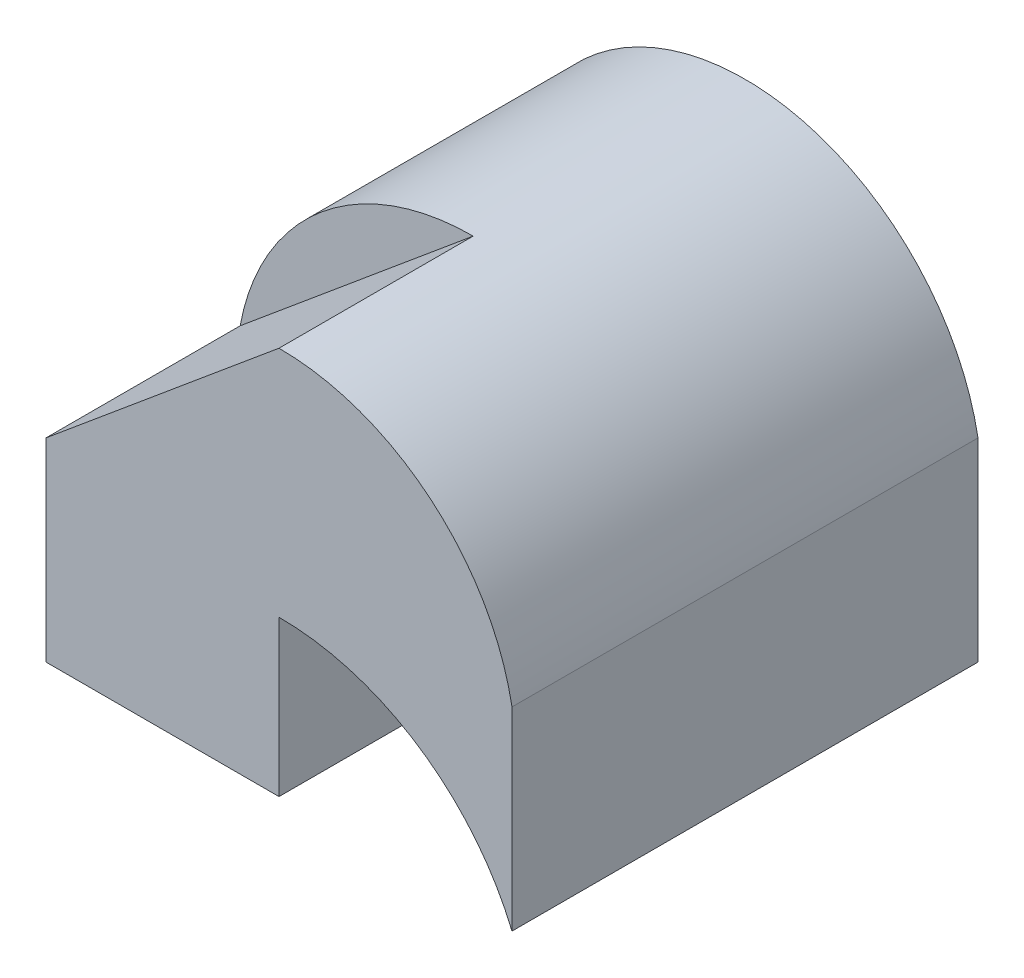
from build123d import *

# Parameters (mm, degrees)
SKETCH1_W           = 6
SKETCH1_H           = 6
BOSS_EXTRUDE1_DEPTH = 5
CUT_EXTRUDE4_DEPTH  = 12.5
CUT_EXTRUDE5_DEPTH  = 2.5
CUT_EXTRUDE6_DEPTH  = 3.5


with BuildPart() as part:
    # Sketch1 → Boss-Extrude1 (new body)
    with BuildSketch(Plane(origin=(0, 0, 0), x_dir=(1, 0, 0), z_dir=(0, 1, 0))):
        Rectangle(SKETCH1_W, SKETCH1_H)
    extrude(amount=BOSS_EXTRUDE1_DEPTH)

    # Sketch5 → Cut-Extrude4 (cut)
    with BuildSketch(Plane.XY.offset(3)):
        with BuildLine():
            Line((-3, 5), (-3, 2.5))
            ThreePointArc((-3, 2.5), (-1.952562419, 4.293074903), (0, 5))
            Line((0, 5), (-3, 5))
        make_face()
        with BuildLine():
            ThreePointArc((0, 5), (1.952562419, 4.293074903), (3, 2.5))
            Line((3, 2.5), (3, 5))
            Line((3, 5), (0, 5))
        make_face()
        with BuildLine():
            ThreePointArc((3, 0), (1.802775638, 1.454163457), (0, 2))
            Line((0, 2), (0, 0))
            Line((0, 0), (3, 0))
        make_face()
    extrude(amount=-CUT_EXTRUDE4_DEPTH, mode=Mode.SUBTRACT)

    # Sketch6 → Cut-Extrude5 (cut)
    with BuildSketch(Plane.XY.offset(3)):
        with BuildLine():
            Line((-3, 2.5), (0, 5))
            ThreePointArc((0, 5), (-1.952562419, 4.293074903), (-3, 2.5))
        make_face()
    extrude(amount=-CUT_EXTRUDE5_DEPTH, mode=Mode.SUBTRACT)

    # Sketch7 → Cut-Extrude6 (cut)
    with BuildSketch(Plane(origin=(0, 0, -3), x_dir=(-1, 0, 0), z_dir=(0, 0, -1))):
        with BuildLine():
            Line((0, 2), (0, 0))
            Line((0, 0), (3, 0))
            ThreePointArc((3, 0), (1.802775638, 1.454163457), (0, 2))
        make_face()
    extrude(amount=-CUT_EXTRUDE6_DEPTH, mode=Mode.SUBTRACT)


solid = part.part
